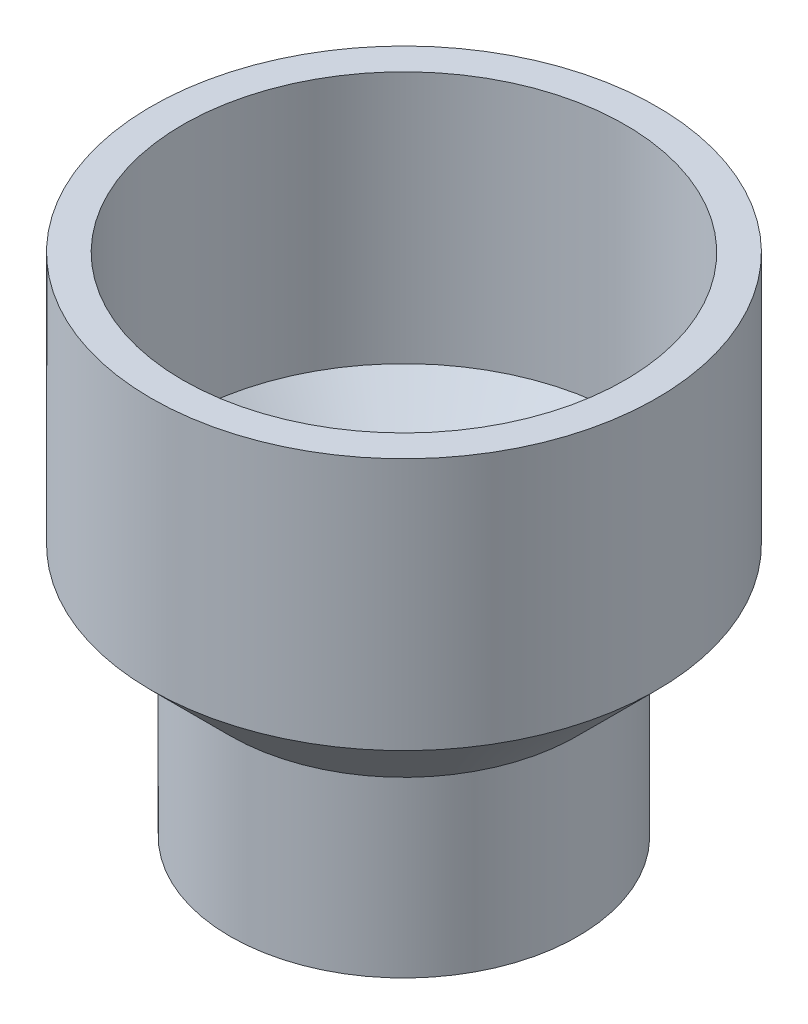
from build123d import *

# Parameters (mm, degrees)
SKETCH1_R           = 34.925
SKETCH1_R_2         = 30.1625
BOSS_EXTRUDE1_DEPTH = 50.8
SKETCH2_R           = 50.8
SKETCH2_R_2         = 44.45
BOSS_EXTRUDE2_DEPTH = 50.8
SKETCH4_R           = 30.1625
SKETCH4_R_2         = 29.21
BOSS_EXTRUDE3_DEPTH = 15.0876
CUT_EXTRUDE1_REACH  = 89.988
SKETCH6_R           = 2.2225


with BuildPart() as part:
    # Sketch1 → Boss-Extrude1 (new body)
    with BuildSketch(Plane(origin=(0, 0, 0), x_dir=(1, 0, 0), z_dir=(0, 1, 0))):
        with Locations(Location((0, 0, 0), (0, 0, 270))):
            Circle(SKETCH1_R)
        with Locations(Location((0, 0, 0), (0, 0, 270))):
            Circle(SKETCH1_R_2, mode=Mode.SUBTRACT)
    extrude(amount=BOSS_EXTRUDE1_DEPTH)



with BuildPart() as body_2:
    # Sketch2 → Boss-Extrude2 (new body)
    with BuildSketch(Plane(origin=(0, 50.8, 0), x_dir=(1, 0, 0), z_dir=(0, 1, 0))):
        with Locations(Location((0, 0, 0), (0, 0, 270))):
            Circle(SKETCH2_R)
        with Locations(Location((0, 0, 0), (0, 0, 270))):
            Circle(SKETCH2_R_2, mode=Mode.SUBTRACT)
    extrude(amount=BOSS_EXTRUDE2_DEPTH)


with BuildPart() as part_1:
    add(part.part)

    add(body_2.part)  # Revolve1 merges body 2
    # Sketch3 → Revolve1 (revolve)
    with BuildSketch(Plane.XY, mode=Mode.PRIVATE) as revolve1_sk:
        Polygon((50.8, 50.8), (34.925, 34.925), (34.925, 50.8), align=None)
    revolve(revolve1_sk.sketch.rotate(Axis((0, 101.6, 0), (0, -1, 0)), 90), axis=Axis((0, 101.6, 0), (0, -1, 0)))

    # Sketch4 → Boss-Extrude3 (add)
    with BuildSketch(Plane(origin=(0, 50.8, 0), x_dir=(1, 0, 0), z_dir=(0, 1, 0))):
        with Locations(Location((0, 0, 0), (0, 0, 270))):
            Circle(SKETCH4_R)
        with Locations(Location((0, 0, 0), (0, 0, 270))):
            Circle(SKETCH4_R_2, mode=Mode.SUBTRACT)
    extrude(amount=-BOSS_EXTRUDE3_DEPTH)

    # Sketch5 → Cut-Revolve1 (revolve, cut)
    with BuildSketch(Plane(origin=(0, 0, 0), x_dir=(0, 0, -1), z_dir=(1, 0, 0))):
        Polygon((-44.45, 50.8), (-29.21, 36.195), (-29.21, 50.8), align=None)
    revolve(axis=Axis((0, 101.6, 0), (0, -1, 0)), mode=Mode.SUBTRACT)

    # Cut-Extrude1: up to this cone (the profile starts inside it)
    cut_extrude1_end = Plane(origin=(0, 50.8, 0), z_dir=(0, 1, 0)).offset(-50.799999) * Cone(1e-06, 192.088, 192.087999, align=(Align.CENTER, Align.CENTER, Align.MIN), mode=Mode.PRIVATE)
    # Sketch6 → Cut-Extrude1 (cut, up to the surface)
    with BuildSketch(Plane(origin=(0, 50.8, 0), x_dir=(-1, 0, 0), z_dir=(0, -1, 0)), mode=Mode.PRIVATE) as cut_extrude1_sk1:
        with Locations(Location((36.068, 0, 0), (0, 0, 237.524024199))):
            Circle(SKETCH6_R)
    cut_extrude1_tool1 = extrude(cut_extrude1_sk1.sketch, amount=CUT_EXTRUDE1_REACH, mode=Mode.PRIVATE) & cut_extrude1_end
    add(cut_extrude1_tool1.solids().sort_by_distance((-36.068, 50.8, 0))[0], mode=Mode.SUBTRACT)


solid = part_1.part
